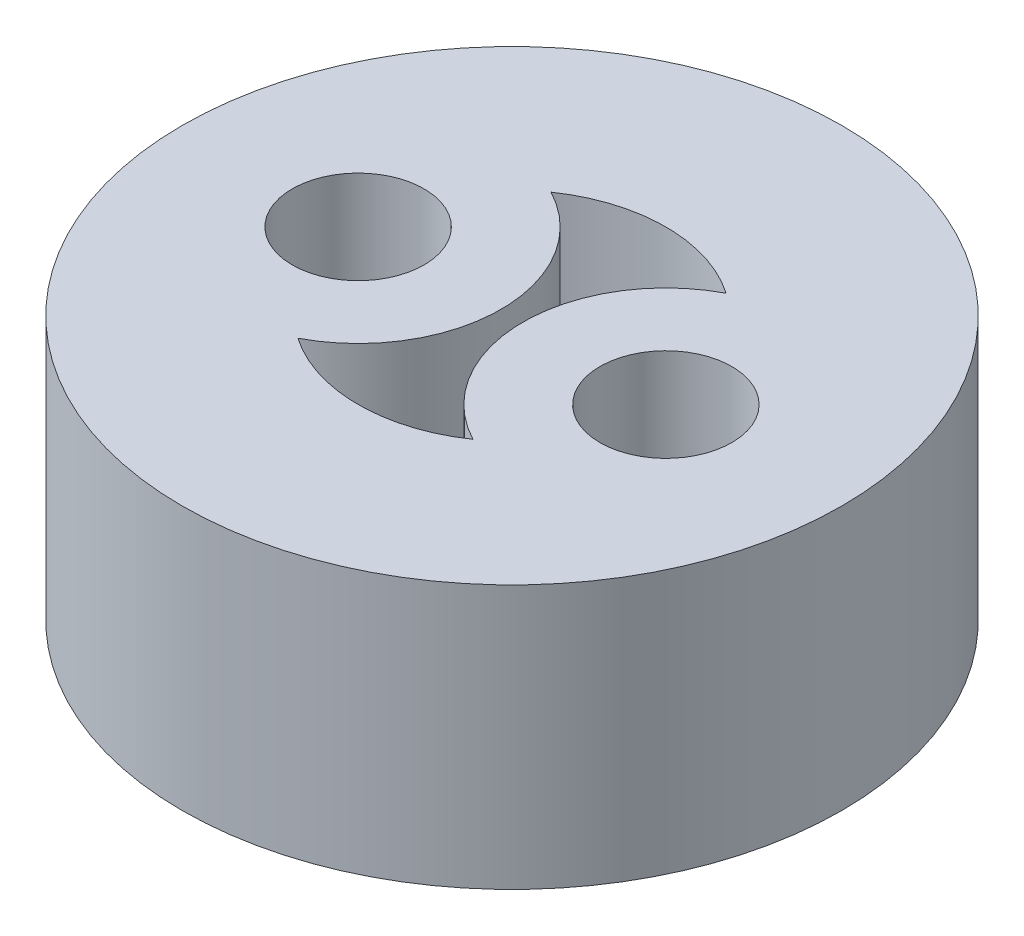
from build123d import *

# Parameters (mm, degrees)
ESQUISSE1_R        = 7.5
ESQUISSE1_R_2      = 1.5
BOSS_EXTRU_1_DEPTH = 6


with BuildPart() as part:
    # Esquisse1 → Boss.-Extru.1 (new body)
    with BuildSketch(Plane(origin=(0, 0, 0), x_dir=(1, 0, 0), z_dir=(0, 1, 0))):
        Circle(ESQUISSE1_R)
        with Locations((-3.5, 0)):
            Circle(ESQUISSE1_R_2, mode=Mode.SUBTRACT)
        with Locations((3.5, 0)):
            Circle(ESQUISSE1_R_2, mode=Mode.SUBTRACT)
        with BuildLine():
            ThreePointArc((1.991071429, 2.878477821), (0.25, 0), (1.991071429, -2.878477821))
            ThreePointArc((1.991071429, -2.878477821), (0, -3.5), (-1.991071429, -2.878477821))
            ThreePointArc((-1.991071429, -2.878477821), (-0.25, 0), (-1.991071429, 2.878477821))
            ThreePointArc((-1.991071429, 2.878477821), (0, 3.5), (1.991071429, 2.878477821))
        make_face(mode=Mode.SUBTRACT)
    extrude(amount=BOSS_EXTRU_1_DEPTH)


solid = part.part
